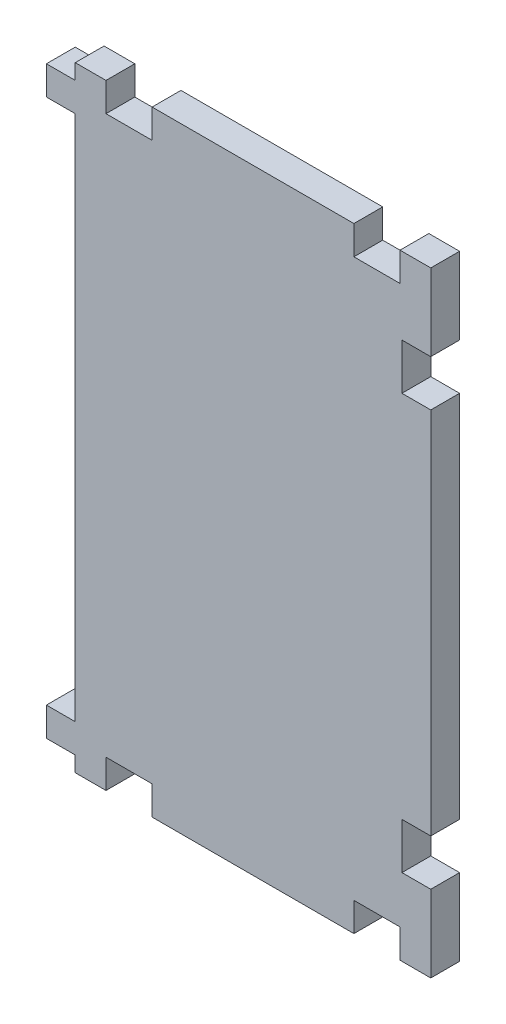
from build123d import *

# Parameters (mm, degrees)
SKETCH2_W           = 4.7625
SKETCH2_H           = 4.7625
BOSS_EXTRUDE1_DEPTH = 4.7625


with BuildPart() as part:
    # Sketch2 → Boss-Extrude1 (new body)
    with BuildSketch(Plane.XY):
        with Locations((-2.38125, -96.67875)):
            Rectangle(SKETCH2_W, SKETCH2_H)
        with Locations((-2.38125, -4.92125)):
            Rectangle(SKETCH2_W, SKETCH2_H)
        Polygon((5.08, 0), (0, 0), (0, -2.54), (0, -7.3025), (0, -94.2975), (0, -99.06), (0, -101.6), (5.08, -101.6), (5.08, -96.8375), (12.7, -96.8375), (12.7, -101.6), (46.0375, -101.6), (46.0375, -96.8375), (53.6575, -96.8375), (53.6575, -101.6), (58.7375, -101.6), (58.7375, -88.9), (53.975, -88.9), (53.975, -81.28), (58.7375, -81.28), (58.7375, -20.32), (53.975, -20.32), (53.975, -12.7), (58.7375, -12.7), (58.7375, 0), (53.6575, 0), (53.6575, -4.7625), (46.0375, -4.7625), (46.0375, 0), (12.7, 0), (12.7, -4.7625), (5.08, -4.7625), align=None)
    extrude(amount=BOSS_EXTRUDE1_DEPTH)


solid = part.part
